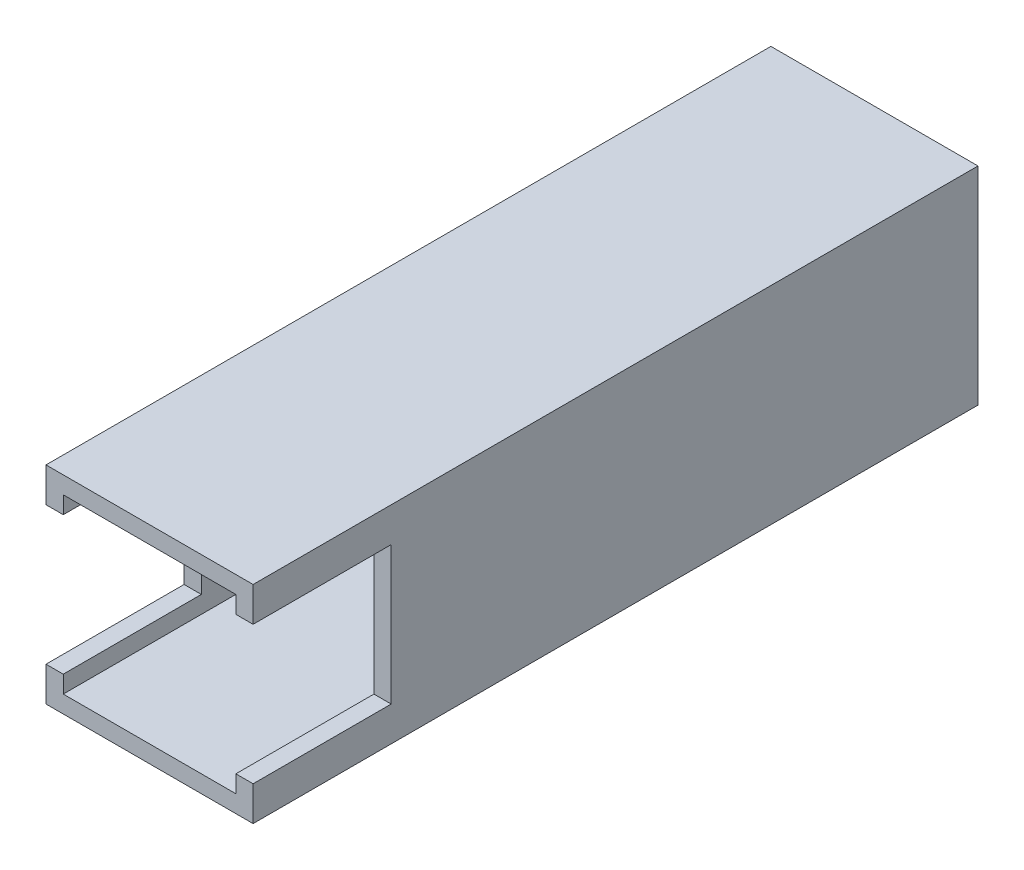
from build123d import *

# Parameters (mm, degrees)
SKETCH1_W           = 38.1
SKETCH1_H           = 133.35
BOSS_EXTRUDE1_DEPTH = 19.05
SKETCH2_W           = 31.75
SKETCH2_H           = 31.75
CUT_EXTRUDE1_DEPTH  = 134.35
SKETCH3_W           = 25.4
SKETCH3_H           = 25.4
CUT_EXTRUDE2_DEPTH  = 39.1


with BuildPart() as part:
    # Sketch1 → Boss-Extrude1 (new body, symmetric)
    with BuildSketch(Plane(origin=(0, 0, 0), x_dir=(1, 0, 0), z_dir=(0, 1, 0))):
        Rectangle(SKETCH1_W, SKETCH1_H)
    extrude(amount=BOSS_EXTRUDE1_DEPTH, both=True)

    # Sketch2 → Cut-Extrude1 (cut, through all)
    with BuildSketch(Plane.XY.offset(66.675)):
        Rectangle(SKETCH2_W, SKETCH2_H)
    extrude(amount=-CUT_EXTRUDE1_DEPTH, mode=Mode.SUBTRACT)

    # Sketch3 → Cut-Extrude2 (cut, through all)
    with BuildSketch(Plane(origin=(19.05, 0, 0), x_dir=(0, 0, -1), z_dir=(1, 0, 0))):
        with Locations((-53.975, 0)):
            Rectangle(SKETCH3_W, SKETCH3_H)
    extrude(amount=-CUT_EXTRUDE2_DEPTH, mode=Mode.SUBTRACT)


solid = part.part
